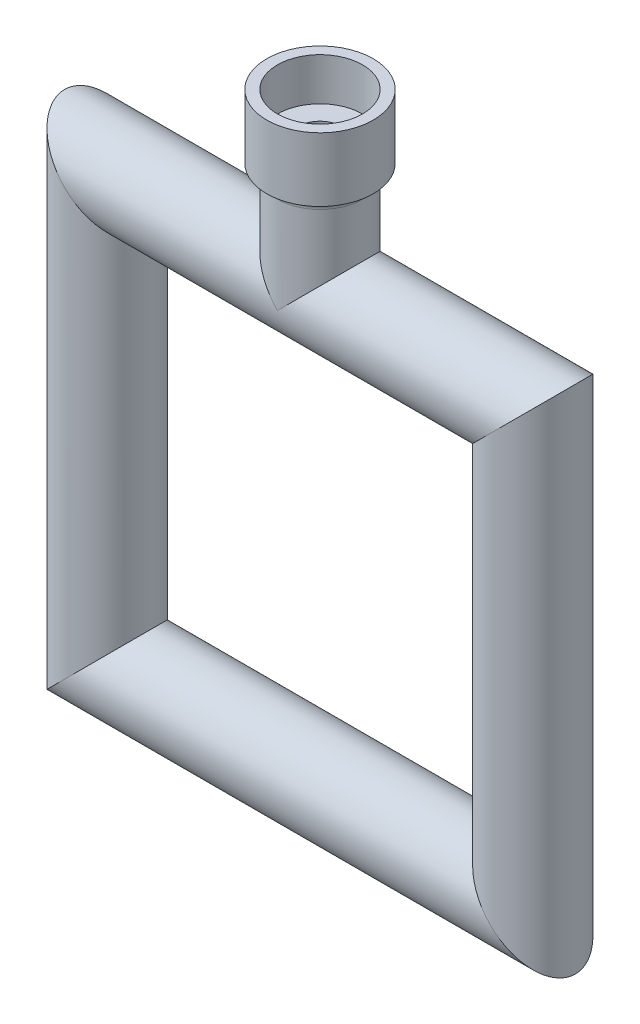
from build123d import *

# Parameters (mm, degrees)
SWEEP5_PROFILE_R         = 8
TAGLIO_ESTRUSIONE1_REACH = 114
SCHIZZO15_R              = 4


with BuildPart() as part:
    # Sweep5: sweep along a path in Schizzo1
    with BuildLine(Plane.XY) as sweep5_path:
        Line((-132.062548693, 77.708245302), (-212.062548693, 77.708245302))
        Line((-212.062548693, 77.708245302), (-212.062548693, -2.291754698))
        Line((-212.062548693, -2.291754698), (-132.062548693, -2.291754698))
        Line((-132.062548693, -2.291754698), (-132.062548693, 77.708245302))
    # Sweep5 profile (on start of the path) → Sweep5 (sweep)
    with BuildSketch(Plane(origin=(-132.062548693, 77.708245302, 0), x_dir=(0, -1, 0), z_dir=(-1, 0, 0))):
        Circle(SWEEP5_PROFILE_R)
    sweep(path=sweep5_path.line, transition=Transition.RIGHT)

    # Schizzo14 → Rivoluzione1 (revolve)
    with BuildSketch(Plane(origin=(-172.062548693, 0, 0), x_dir=(0, -1, 0), z_dir=(1, 0, 0))):
        with BuildLine():
            Line((-77.708245302, 0), (-101.708245302, 0))
            Line((-101.708245302, 0), (-101.708245302, 8))
            Line((-101.708245302, 8), (-109.708245302, 8))
            Line((-109.708245302, 8), (-109.708245302, 10))
            Line((-109.708245302, 10), (-97.708245302, 10))
            Line((-97.708245302, 10), (-97.708245302, 9.9))
            ThreePointArc((-97.708245302, 9.9), (-97.151748186, 8.556497116), (-95.808245302, 8))
            Line((-95.808245302, 8), (-77.708245302, 8))
            Line((-77.708245302, 8), (-77.708245302, 0))
        make_face()
    revolve(axis=Axis((-172.062548693, 29.552378968, 0), (0, 1, 0)))

    # Schizzo15 → Taglio-Estrusione1 (cut, up to next)
    with BuildSketch(Plane(origin=(0, 101.708245302, 0), x_dir=(1, 0, 0), z_dir=(0, 1, 0)), mode=Mode.PRIVATE) as taglio_estrusione1_sk1:
        with Locations((-172.062548693, 0)):
            Circle(SCHIZZO15_R)
    taglio_estrusione1_tool1 = extrude(taglio_estrusione1_sk1.sketch, amount=-TAGLIO_ESTRUSIONE1_REACH, mode=Mode.PRIVATE) & part.part
    add(taglio_estrusione1_tool1.solids().sort_by_distance((-172.062549, 101.708245, 0))[0], mode=Mode.SUBTRACT)


solid = part.part
